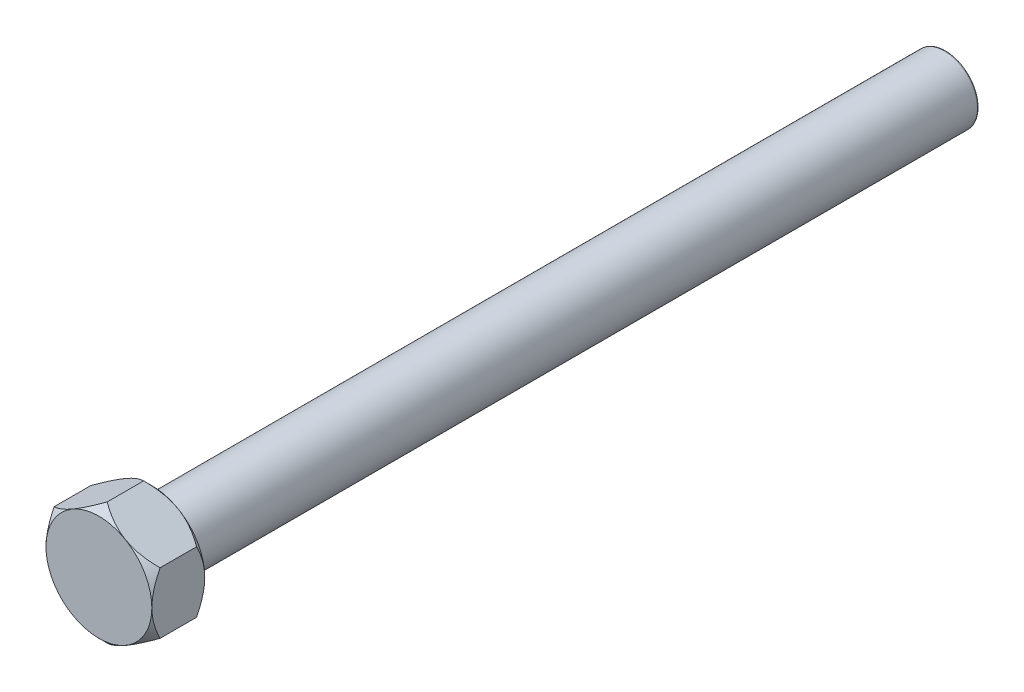
from build123d import *

# Parameters (mm, degrees)
EXTRUDE_1_DEPTH = 4
SKETCH_3_R      = 2.5
EXTRUDE_2_DEPTH = 60
FILLET_2_R      = 0.12


with BuildPart() as part:
    # 草图1 → 凸台-拉伸1 (new body)
    with BuildSketch(Plane.XY):
        Polygon((0, 4.618802154), (-4, 2.309401077), (-4, -2.309401077), (0, -4.618802154), (4, -2.309401077), (4, 2.309401077), align=None)
    extrude(amount=EXTRUDE_1_DEPTH)

    # 草图2 → 切除-旋转1 (revolve, cut)
    with BuildSketch(Plane(origin=(0, 0, 0), x_dir=(0, 0, -1), z_dir=(1, 0, 0))):
        Polygon((0, 4.618802154), (0, 3.998802154), (-0.62, 4.618802154), align=None)
        Polygon((-3.38, 4.618802154), (-4, 3.998802154), (-4, 4.618802154), align=None)
    revolve(axis=Axis((0, 0, 0), (0, 0, -1)), mode=Mode.SUBTRACT)

    # 草图3 → 凸台-拉伸2 (add)
    with BuildSketch(Plane(origin=(0, 0, 0), x_dir=(-1, 0, 0), z_dir=(0, 0, -1))):
        Circle(SKETCH_3_R)
    extrude(amount=EXTRUDE_2_DEPTH)

    # 圆角2
    fillet_2_edges = [part.edges().sort_by_distance(p)[0] for p in [
        (2.5, 0, -60),
    ]]
    fillet(fillet_2_edges, radius=FILLET_2_R)


solid = part.part
